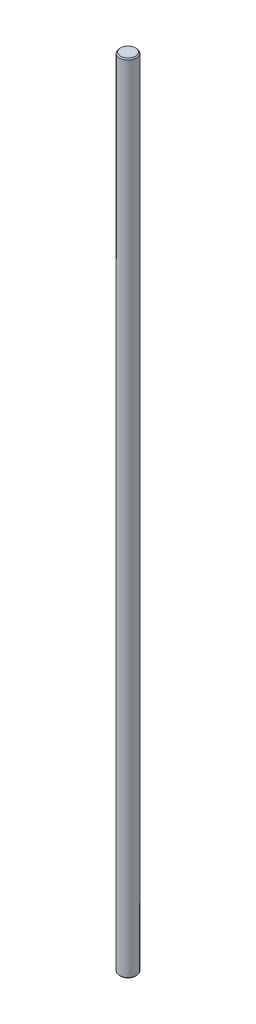
from build123d import *

# Parameters (mm, degrees)
BOSS_EXTRUDE1_DEPTH      = 190
BOSS_EXTRUDE1_DEPTH_BACK = 190
SKETCH1_R                = 4
CHAMFER1_SIZE            = 0.5


with BuildPart() as part:
    # Sketch1 → Boss-Extrude1 (new, two sides: drawn at the far end of the back side and taken through both)
    with BuildSketch(Plane(origin=(0, 0, 0), x_dir=(1, 0, 0), z_dir=(0, 1, 0)).offset(-BOSS_EXTRUDE1_DEPTH_BACK)):
        Circle(SKETCH1_R)
    extrude(amount=BOSS_EXTRUDE1_DEPTH + BOSS_EXTRUDE1_DEPTH_BACK)

    # Chamfer1
    chamfer1_edges = [part.edges().sort_by_distance(p)[0] for p in [
        (-4, -190, 0),
        (-4, 190, 0),
    ]]
    chamfer(chamfer1_edges, length=CHAMFER1_SIZE)


solid = part.part
